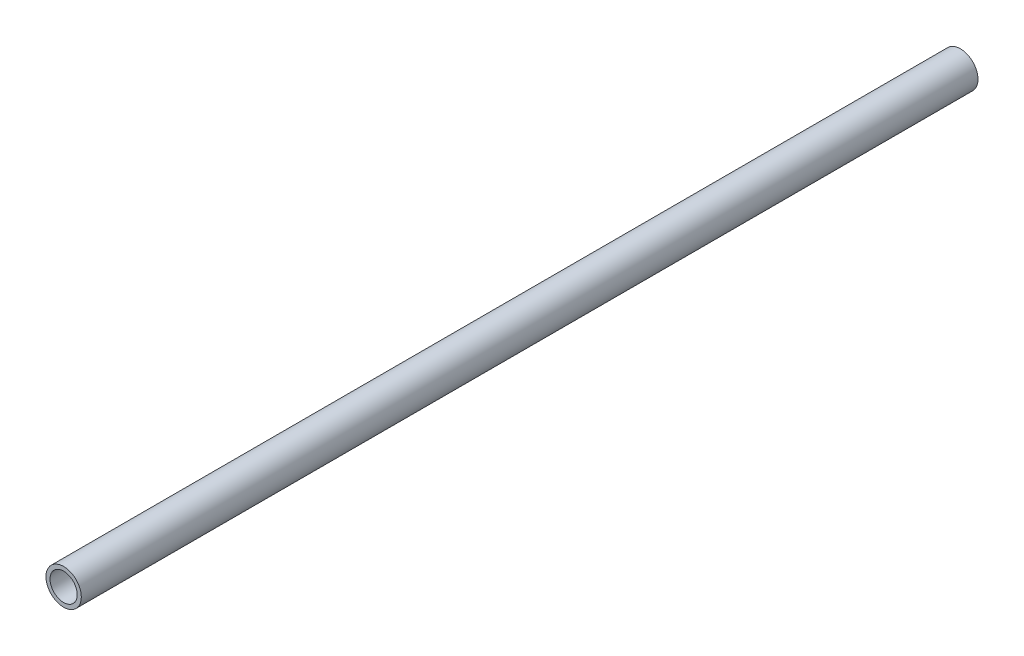
from build123d import *

# Parameters (mm, degrees)
CROQUIS1_R              = 6.5
CROQUIS1_R_2            = 5
SALIENTE_EXTRUIR1_DEPTH = 165


with BuildPart() as part:
    # Croquis1 → Saliente-Extruir1 (new body, symmetric)
    with BuildSketch(Plane.XY):
        Circle(CROQUIS1_R)
        Circle(CROQUIS1_R_2, mode=Mode.SUBTRACT)
    extrude(amount=SALIENTE_EXTRUIR1_DEPTH, both=True)


solid = part.part
